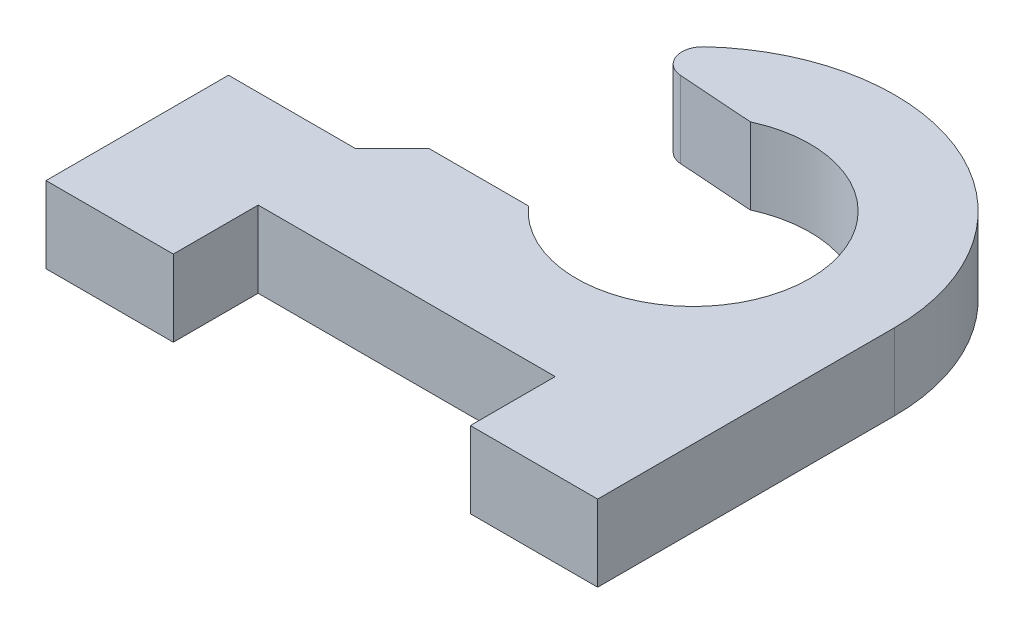
from build123d import *

# Parameters (mm, degrees)
SKETCH1_R           = 2.75
BOSS_EXTRUDE1_DEPTH = 1.8
CUT_EXTRUDE1_DEPTH  = 1.8
FILLET1_R           = 0.5


with BuildPart() as part:
    # Sketch1 → Boss-Extrude1 (new body)
    with BuildSketch(Plane(origin=(0, 0, 0), x_dir=(1, 0, 0), z_dir=(0, 1, 0))):
        with BuildLine():
            Line((4.75, 0), (4.75, -5))
            Line((4.75, -5), (4.75, -7))
            Line((4.75, -7), (1.75, -7))
            Line((1.75, -7), (1.75, -5))
            Line((1.75, -5), (-5.25, -5))
            Line((-5.25, -5), (-5.25, -7))
            Line((-5.25, -7), (-8.25, -7))
            Line((-8.25, -7), (-8.25, -5))
            Line((-8.25, -5), (-8.25, -2.7))
            Line((-8.25, -2.7), (-5.25, -2.7))
            Line((-5.25, -2.7), (-4.382350157, -1.832350157))
            ThreePointArc((-4.382350157, -1.832350157), (-0.93443479, 4.657180652), (4.75, 0))
        make_face()
        Circle(SKETCH1_R, mode=Mode.SUBTRACT)
    extrude(amount=BOSS_EXTRUDE1_DEPTH)

    # Sketch2 → Cut-Extrude1 (cut)
    with BuildSketch(Plane(origin=(0, 1.8, 0), x_dir=(1, 0, 0), z_dir=(0, 1, 0))):
        Polygon((-5, 2.767649843), (0, 2.418015783), (0, -1.832350157), (-5, -1.832350157), align=None)
    extrude(amount=-CUT_EXTRUDE1_DEPTH, mode=Mode.SUBTRACT)

    # Fillet1
    fillet1_edges = [part.edges().sort_by_distance(p)[0] for p in [
        (-3.913732442, 0.9, -2.691690615),
    ]]
    fillet(fillet1_edges, radius=FILLET1_R)


solid = part.part
